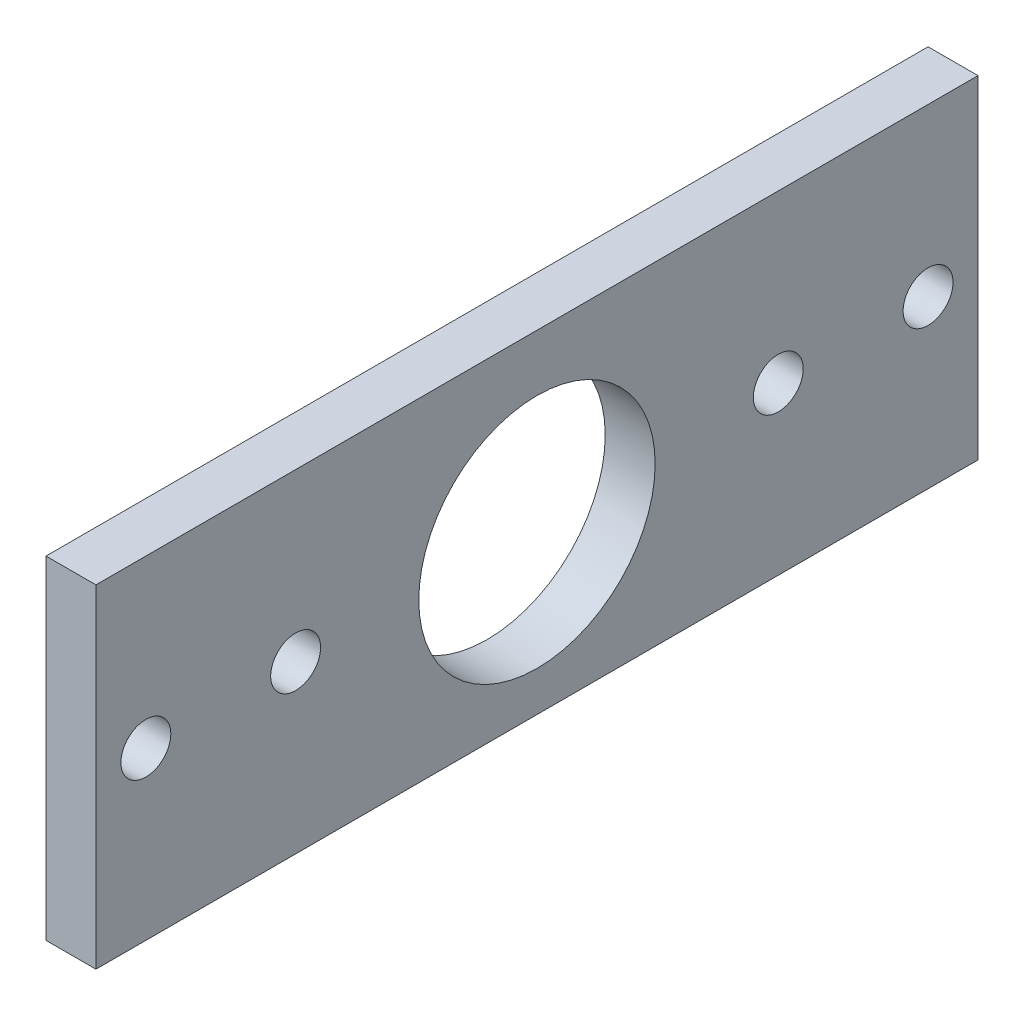
from build123d import *

# Parameters (mm, degrees)
SKETCH_1_W      = 53
SKETCH_1_H      = 20
SKETCH_1_R      = 1.5
SKETCH_1_R_2    = 7.101830236
EXTRUDE_1_DEPTH = 3


with BuildPart() as part:
    # 草图1 → 凸台-拉伸1 (new body)
    with BuildSketch(Plane(origin=(0, 0, 0), x_dir=(0, 0, -1), z_dir=(1, 0, 0))):
        with Locations((26.5, 10)):
            Rectangle(SKETCH_1_W, SKETCH_1_H)
        with Locations((3, 10)):
            Circle(SKETCH_1_R, mode=Mode.SUBTRACT)
        with Locations((12, 10)):
            Circle(SKETCH_1_R, mode=Mode.SUBTRACT)
        with Locations((26.5, 9.5)):
            Circle(SKETCH_1_R_2, mode=Mode.SUBTRACT)
        with Locations((41, 10)):
            Circle(SKETCH_1_R, mode=Mode.SUBTRACT)
        with Locations((50, 10)):
            Circle(SKETCH_1_R, mode=Mode.SUBTRACT)
    extrude(amount=EXTRUDE_1_DEPTH)


solid = part.part
